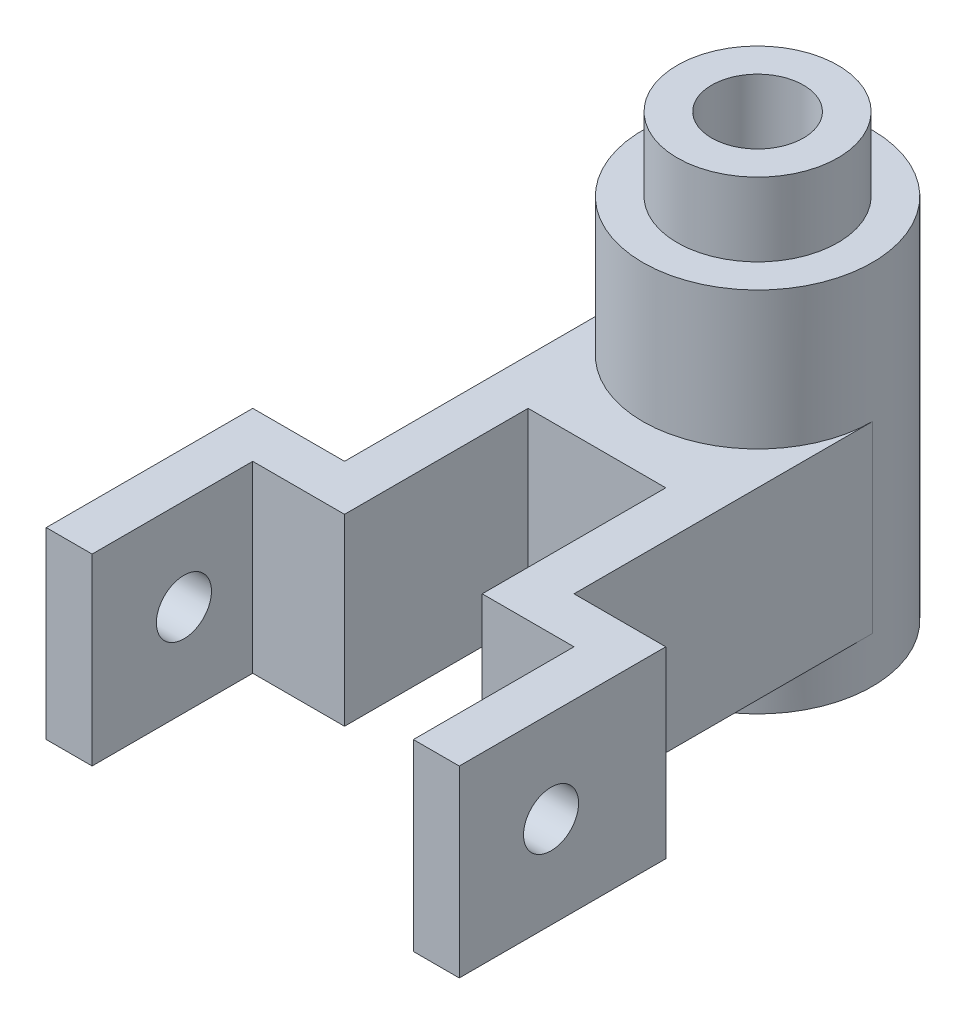
from build123d import *

# Parameters (mm, degrees)
SKETCH1_R           = 25
BOSS_EXTRUDE1_DEPTH = 80
SKETCH2_R           = 17.5
BOSS_EXTRUDE2_DEPTH = 16
SKETCH3_R           = 10
CUT_EXTRUDE1_DEPTH  = 200
BOSS_EXTRUDE3_START = 10
BOSS_EXTRUDE3_DEPTH = 40
SKETCH5_R           = 6
CUT_EXTRUDE2_DEPTH  = 100


with BuildPart() as part:
    # Sketch1 → Boss-Extrude1 (new body)
    with BuildSketch(Plane(origin=(0, 0, 0), x_dir=(1, 0, 0), z_dir=(0, 1, 0))):
        Circle(SKETCH1_R)
    extrude(amount=BOSS_EXTRUDE1_DEPTH)

    # Sketch2 → Boss-Extrude2 (add)
    with BuildSketch(Plane(origin=(0, 80, 0), x_dir=(1, 0, 0), z_dir=(0, 1, 0))):
        Circle(SKETCH2_R)
    extrude(amount=BOSS_EXTRUDE2_DEPTH)

    # Sketch3 → Cut-Extrude1 (cut)
    with BuildSketch(Plane(origin=(0, 96, 0), x_dir=(1, 0, 0), z_dir=(0, 1, 0))):
        Circle(SKETCH3_R)
    extrude(amount=-CUT_EXTRUDE1_DEPTH, mode=Mode.SUBTRACT)

    # Sketch4 → Boss-Extrude3 (add)
    with BuildSketch(Plane(origin=(0, 0, 0), x_dir=(1, 0, 0), z_dir=(0, 1, 0)).offset(BOSS_EXTRUDE3_START)):
        with BuildLine():
            Line((-25, 0), (-25, -65))
            Line((-25, -65), (-45, -65))
            Line((-45, -65), (-45, -110))
            Line((-45, -110), (-35, -110))
            Line((-35, -110), (-35, -75))
            Line((-35, -75), (-15, -75))
            Line((-15, -75), (-15, -35))
            Line((-15, -35), (0, -35))
            Line((0, -35), (15, -35))
            Line((15, -35), (15, -75))
            Line((15, -75), (35, -75))
            Line((35, -75), (35, -110))
            Line((35, -110), (45, -110))
            Line((45, -110), (45, -65))
            Line((45, -65), (25, -65))
            Line((25, -65), (25, 0))
            ThreePointArc((25, 0), (0, -25), (-25, 0))
        make_face()
    extrude(amount=BOSS_EXTRUDE3_DEPTH)

    # Sketch5 → Cut-Extrude2 (cut)
    with BuildSketch(Plane(origin=(45, 0, 0), x_dir=(0, 0, -1), z_dir=(1, 0, 0))):
        with Locations((-90, 30)):
            Circle(SKETCH5_R)
    extrude(amount=-CUT_EXTRUDE2_DEPTH, mode=Mode.SUBTRACT)


solid = part.part
